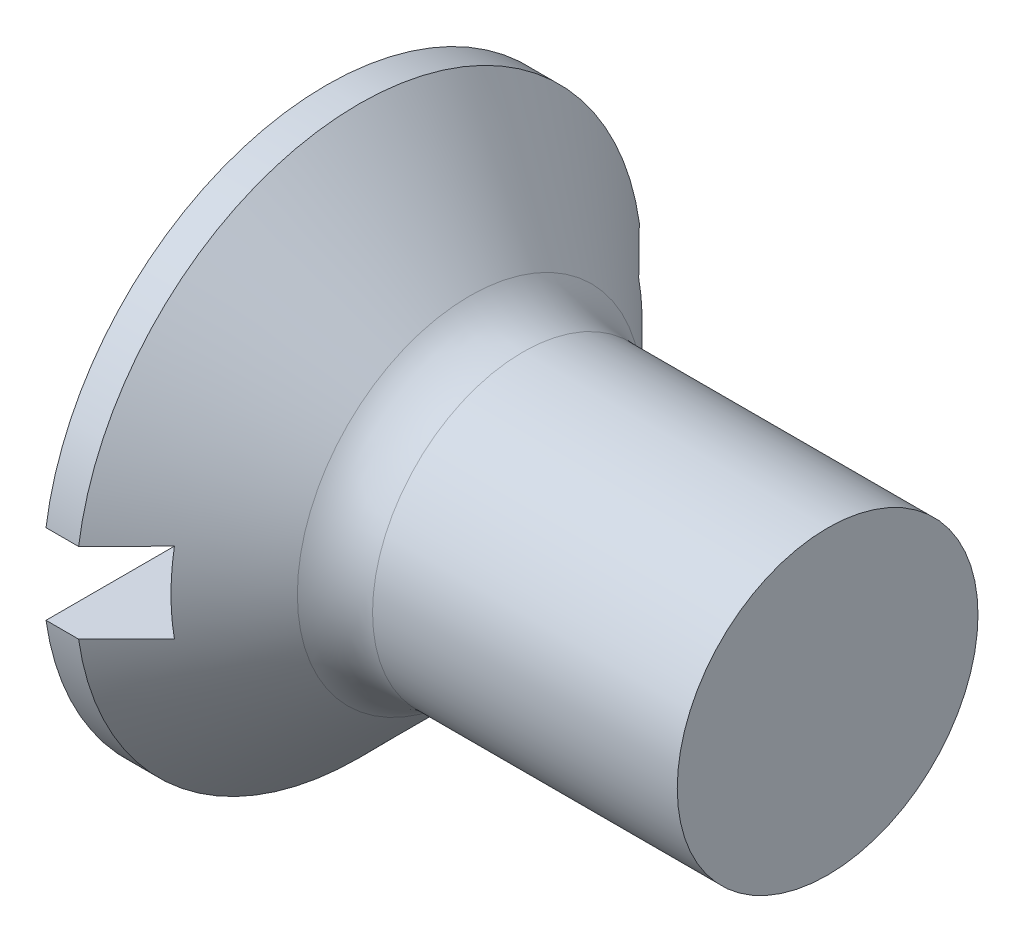
from build123d import *

# Parameters (mm, degrees)
FILLET1_R  = 1.5
SKETCH2_W  = 11.3
SKETCH2_H  = 1.6
SLOT_DEPTH = 1.6


with BuildPart() as part:
    # BodySke → Base-Revolve (revolve)
    with BuildSketch(Plane.XY, mode=Mode.PRIVATE) as base_revolve_sk:
        Polygon((0, 0), (0, 5.65), (0.65, 5.65), (3.3, 3), (10, 3), (10, 0), align=None)
    revolve(base_revolve_sk.sketch.rotate(Axis((-6.35, 0, 0), (1, 0, 0)), 90), axis=Axis((-6.35, 0, 0), (1, 0, 0)))  # turned: the seam where the file's is

    # Fillet1
    fillet1_edges = [part.edges().sort_by_distance(p)[0] for p in [
        (3.3, 0, -3),
    ]]
    fillet(fillet1_edges, radius=FILLET1_R)

    # Sketch2 → Slot (cut)
    with BuildSketch(Plane.ZY):
        Rectangle(SKETCH2_W, SKETCH2_H)
    extrude(amount=-SLOT_DEPTH, mode=Mode.SUBTRACT)


solid = part.part
